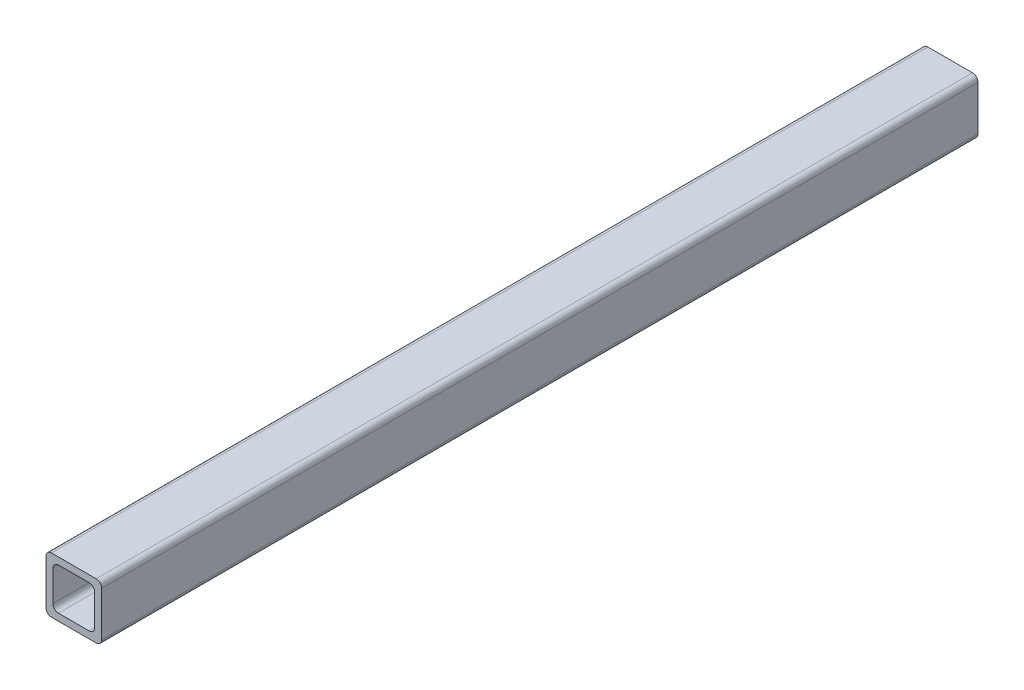
from build123d import *

# Parameters (mm, degrees)
SALIENTE_EXTRUIR1_DEPTH = 400


with BuildPart() as part:
    # Croquis1 → Saliente-Extruir1 (new body)
    with BuildSketch(Plane.XY):
        with BuildLine():
            Line((-10.2, -12.7), (10.2, -12.7))
            ThreePointArc((10.2, -12.7), (11.967766953, -11.967766953), (12.7, -10.2))
            Line((12.7, -10.2), (12.7, 10.2))
            ThreePointArc((12.7, 10.2), (11.967766953, 11.967766953), (10.2, 12.7))
            Line((10.2, 12.7), (-10.2, 12.7))
            ThreePointArc((-10.2, 12.7), (-11.967766953, 11.967766953), (-12.7, 10.2))
            Line((-12.7, 10.2), (-12.7, -10.2))
            ThreePointArc((-12.7, -10.2), (-11.967766953, -11.967766953), (-10.2, -12.7))
        make_face()
        with BuildLine():
            Line((-7.025, -9.525), (7.025, -9.525))
            ThreePointArc((7.025, -9.525), (8.792766953, -8.792766953), (9.525, -7.025))
            Line((9.525, -7.025), (9.525, 7.025))
            ThreePointArc((9.525, 7.025), (8.792766953, 8.792766953), (7.025, 9.525))
            Line((7.025, 9.525), (-7.025, 9.525))
            ThreePointArc((-7.025, 9.525), (-8.792766953, 8.792766953), (-9.525, 7.025))
            Line((-9.525, 7.025), (-9.525, -7.025))
            ThreePointArc((-9.525, -7.025), (-8.792766953, -8.792766953), (-7.025, -9.525))
        make_face(mode=Mode.SUBTRACT)
    extrude(amount=SALIENTE_EXTRUIR1_DEPTH)


solid = part.part
